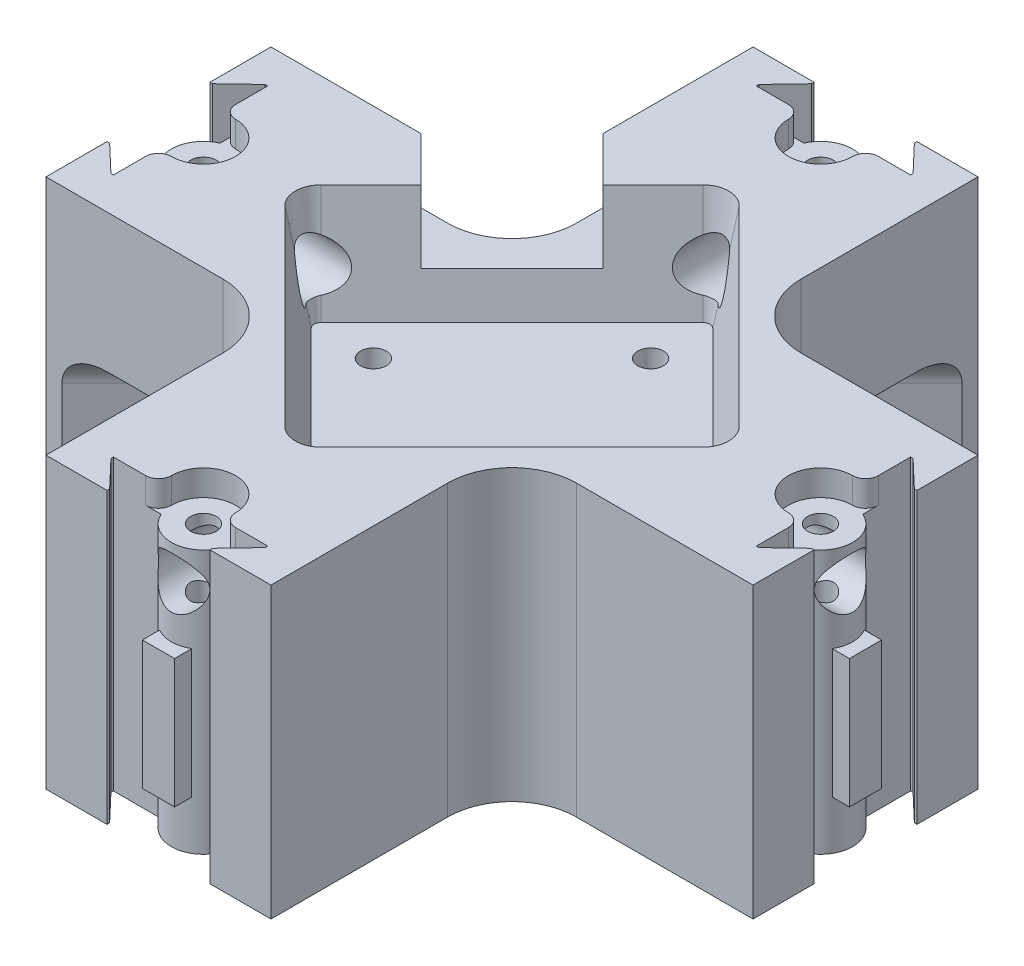
from build123d import *

# Parameters (mm, degrees)
BOSS_EXTRUDE1_DEPTH      = 45
CUT_EXTRUDE1_DEPTH       = 34.5
CUT_EXTRUDE2_DEPTH       = 46
CUT_EXTRUDE3_DEPTH       = 4
CIRPATTERN1_COUNT        = 4
SKETCH5_W                = 5
SKETCH5_H                = 20
BOSS_EXTRUDE2_DEPTH      = 4
SKETCH6_R                = 5
SKETCH6_R_2              = 2
BOSS_EXTRUDE3_DEPTH      = 45
SKETCH6_4_R              = 5
SKETCH6_4_R_2            = 2
CUT_EXTRUDE4_DEPTH       = 4
SKETCH6_5_R              = 2
CUT_EXTRUDE5_DEPTH       = 46
SKETCH5_3_W              = 5
SKETCH5_3_H              = 20
BOSS_EXTRUDE5_DEPTH      = 5
CIRPATTERN5_COUNT        = 4
CIRPATTERN6_COUNT        = 4
BOSS_EXTRUDE6_DEPTH      = 11
CUT_EXTRUDE6_DEPTH       = 16.5
CUT_EXTRUDE6_TAPER       = 10
CUT_EXTRUDE8_START       = -106
SKETCH5_7_R              = 4
CUT_EXTRUDE8_DEPTH       = 112
FILLET2_R                = 5
SKETCH14_R               = 2
CUT_EXTRUDE9_DEPTH       = 29.5000001
SKETCH17_W               = 20
SKETCH17_H               = 20
CUT_EXTRUDE11_DEPTH      = 10
CUT_EXTRUDE11_DEPTH_BACK = 15


with BuildPart() as part:
    # Sketch1 → Boss-Extrude1 (new body)
    with BuildSketch(Plane(origin=(0, 0, 0), x_dir=(1, 0, 0), z_dir=(0, 1, 0))):
        with BuildLine():
            Line((17.41755235, 71.354805723), (17.41755235, 43.854805723))
            ThreePointArc((17.41755235, 43.854805723), (20.346484538, 36.783737911), (27.41755235, 33.854805723))
            Line((27.41755235, 33.854805723), (54.91755235, 33.854805723))
            Line((54.91755235, 33.854805723), (54.91755235, -1.145194277))
            Line((54.91755235, -1.145194277), (27.41755235, -1.145194277))
            ThreePointArc((27.41755235, -1.145194277), (20.346484538, -4.074126465), (17.41755235, -11.145194277))
            Line((17.41755235, -11.145194277), (17.41755235, -38.645194277))
            Line((17.41755235, -38.645194277), (-17.58244765, -38.645194277))
            Line((-17.58244765, -38.645194277), (-17.58244765, -11.145194277))
            ThreePointArc((-17.58244765, -11.145194277), (-20.511379838, -4.074126465), (-27.58244765, -1.145194277))
            Line((-27.58244765, -1.145194277), (-55.08244765, -1.145194277))
            Line((-55.08244765, -1.145194277), (-55.08244765, 33.854805723))
            Line((-55.08244765, 33.854805723), (-27.58244765, 33.854805723))
            ThreePointArc((-27.58244765, 33.854805723), (-20.511379838, 36.783737911), (-17.58244765, 43.854805723))
            Line((-17.58244765, 43.854805723), (-17.58244765, 71.354805723))
            Line((-17.58244765, 71.354805723), (17.41755235, 71.354805723))
        make_face()
    extrude(amount=BOSS_EXTRUDE1_DEPTH)

    # Sketch1_3 → Cut-Extrude1 (cut)
    with BuildSketch(Plane(origin=(0, 0, 0), x_dir=(1, 0, 0), z_dir=(0, 1, 0))):
        with BuildLine():
            Line((17.41755235, 68.856591392), (-52.584233319, -1.145194277))
            Line((-52.584233319, -1.145194277), (-27.58244765, -1.145194277))
            ThreePointArc((-27.58244765, -1.145194277), (-20.511379838, -4.074126465), (-17.58244765, -11.145194277))
            Line((-17.58244765, -11.145194277), (-17.58244765, -36.146979946))
            Line((-17.58244765, -36.146979946), (52.419338019, 33.854805723))
            Line((52.419338019, 33.854805723), (27.41755235, 33.854805723))
            ThreePointArc((27.41755235, 33.854805723), (23.590718027, 34.616010398), (20.346484538, 36.783737911))
            ThreePointArc((20.346484538, 36.783737911), (18.178757025, 40.027971399), (17.41755235, 43.854805723))
            Line((17.41755235, 43.854805723), (17.41755235, 68.856591392))
        make_face()
    extrude(amount=CUT_EXTRUDE1_DEPTH, mode=Mode.SUBTRACT)

    # Sketch3 → Cut-Extrude2 (cut, through all)
    with BuildSketch(Plane(origin=(0, 45, 0), x_dir=(1, 0, 0), z_dir=(0, 1, 0))):
        Polygon((-55.08244765, 16.354805723), (-55.08244765, 8.354805723), (-54.68244765, 8.354805723), (-50.48244765, 4.354805723), (-50.08244765, 4.354805723), (-50.08244765, 9.354805723), (-50.08244765, 16.354805723), align=None)
        Polygon((-55.08244765, 24.354805723), (-55.08244765, 16.354805723), (-50.08244765, 16.354805723), (-50.08244765, 23.354805754), (-50.08244765, 28.354805723), (-50.48244765, 28.354805723), (-54.68244765, 24.354805723), align=None)
    cut_extrude2 = extrude(amount=-CUT_EXTRUDE2_DEPTH, mode=Mode.SUBTRACT)

    # Sketch3_3 → Cut-Extrude3 (cut)
    with BuildSketch(Plane(origin=(0, 45, 0), x_dir=(1, 0, 0), z_dir=(0, 1, 0))):
        with BuildLine():
            Line((-50.08244765, 23.354805754), (-50.08244765, 16.354805723))
            Line((-50.08244765, 16.354805723), (-50.08244765, 9.354805723))
            ThreePointArc((-50.08244765, 9.354805723), (-49.496661212, 10.769019285), (-48.08244765, 11.354805723))
            ThreePointArc((-48.08244765, 11.354805723), (-43.08244765, 16.354805723), (-48.08244765, 21.354805723))
            ThreePointArc((-48.08244765, 21.354805723), (-49.496661223, 21.940592172), (-50.08244765, 23.354805754))
        make_face()
    cut_extrude3 = extrude(amount=-CUT_EXTRUDE3_DEPTH, mode=Mode.SUBTRACT)

    # CirPattern1: Cut-Extrude2, Cut-Extrude3 ×4 about axis
    cirpattern1_axis = Axis((-0.08244765, 0, -16.354805723), (0, 1, 0))
    for i in range(1, CIRPATTERN1_COUNT):
        add(cut_extrude2.rotate(cirpattern1_axis, i * 360 / CIRPATTERN1_COUNT), mode=Mode.SUBTRACT)
        add(cut_extrude3.rotate(cirpattern1_axis, i * 360 / CIRPATTERN1_COUNT), mode=Mode.SUBTRACT)

    # Sketch5 → Boss-Extrude2 (add)
    with BuildSketch(Plane.XY.offset(33.645194277)):
        with Locations((-0.08244765, 17.6)):
            Rectangle(SKETCH5_W, SKETCH5_H)
    extrude(amount=BOSS_EXTRUDE2_DEPTH)

    # Sketch6 → Boss-Extrude3 (add, through all)
    with BuildSketch(Plane(origin=(0, 45, 0), x_dir=(1, 0, 0), z_dir=(0, 1, 0))):
        with Locations((47.91755235, 16.354805723)):
            Circle(SKETCH6_R)
        with Locations((47.91755235, 16.354805723)):
            Circle(SKETCH6_R_2, mode=Mode.SUBTRACT)
    boss_extrude3 = extrude(amount=-BOSS_EXTRUDE3_DEPTH)

    # Sketch6_4 → Cut-Extrude4 (cut)
    with BuildSketch(Plane(origin=(0, 45, 0), x_dir=(1, 0, 0), z_dir=(0, 1, 0))):
        with Locations((47.91755235, 16.354805723)):
            Circle(SKETCH6_4_R)
        with Locations((47.91755235, 16.354805723)):
            Circle(SKETCH6_4_R_2, mode=Mode.SUBTRACT)
    cut_extrude4 = extrude(amount=-CUT_EXTRUDE4_DEPTH, mode=Mode.SUBTRACT)

    # Sketch6_5 → Cut-Extrude5 (cut, through all)
    with BuildSketch(Plane(origin=(0, 45, 0), x_dir=(1, 0, 0), z_dir=(0, 1, 0))):
        with Locations((47.91755235, 16.354805723)):
            Circle(SKETCH6_5_R)
    cut_extrude5 = extrude(amount=-CUT_EXTRUDE5_DEPTH, mode=Mode.SUBTRACT)

    # Sketch5_3 → Boss-Extrude5 (add)
    with BuildSketch(Plane.XY.offset(33.645194277)):
        with Locations((-0.08244765, 17.6)):
            Rectangle(SKETCH5_3_W, SKETCH5_3_H)
    boss_extrude5 = extrude(amount=BOSS_EXTRUDE5_DEPTH)

    # CirPattern5: Boss-Extrude3, Cut-Extrude4, Cut-Extrude5 ×4 about axis
    cirpattern5_axis = Axis((-0.08244765, 0, -16.354805723), (0, 1, 0))
    for i in range(1, CIRPATTERN5_COUNT):
        add(boss_extrude3.rotate(cirpattern5_axis, i * 360 / CIRPATTERN5_COUNT))
        add(cut_extrude4.rotate(cirpattern5_axis, i * 360 / CIRPATTERN5_COUNT), mode=Mode.SUBTRACT)
        add(cut_extrude5.rotate(cirpattern5_axis, i * 360 / CIRPATTERN5_COUNT), mode=Mode.SUBTRACT)

    # CirPattern6: Boss-Extrude5 ×4 about axis
    cirpattern6_axis = Axis((-0.08244765, 0, -16.354805723), (0, 1, 0))
    for i in range(1, CIRPATTERN6_COUNT):
        add(boss_extrude5.rotate(cirpattern6_axis, i * 360 / CIRPATTERN6_COUNT))

    # Sketch12 → Boss-Extrude6 (add)
    with BuildSketch(Plane.XZ.offset(-34.5)):
        with BuildLine():
            Line((52.419338019, -33.854805723), (-17.58244765, 36.146979946))
            Line((-17.58244765, 36.146979946), (-17.58244765, 11.145194277))
            ThreePointArc((-17.58244765, 11.145194277), (-20.511379838, 4.074126465), (-27.58244765, 1.145194277))
            Line((-27.58244765, 1.145194277), (-52.584233319, 1.145194277))
            Line((-52.584233319, 1.145194277), (17.41755235, -68.856591392))
            Line((17.41755235, -68.856591392), (17.41755235, -43.855443478))
            ThreePointArc((17.41755235, -43.855443478), (20.346394354, -36.784465852), (27.417297268, -33.855443481))
            Line((27.417297268, -33.855443481), (52.419338019, -33.854805723))
        make_face()
    extrude(amount=BOSS_EXTRUDE6_DEPTH)

    # Sketch6_7 → Cut-Extrude6 (cut)
    with BuildSketch(Plane(origin=(0, 45, 0), x_dir=(1, 0, 0), z_dir=(0, 1, 0))):
        with BuildLine():
            Line((-17.760117179, 34.032475253), (-32.609359584, 19.183232848))
            ThreePointArc((-32.609359584, 19.183232848), (-33.78093246, 16.354805723), (-32.609359584, 13.526378598))
            Line((-32.609359584, 13.526378598), (-2.910874775, -16.172106212))
            ThreePointArc((-2.910874775, -16.172106212), (-0.08244765, -17.343679087), (2.745979475, -16.172106212))
            Line((2.745979475, -16.172106212), (32.444464285, 13.526378598))
            ThreePointArc((32.444464285, 13.526378598), (33.61603716, 16.354805723), (32.444464285, 19.183232848))
            Line((32.444464285, 19.183232848), (2.745979475, 48.881717658))
            ThreePointArc((2.745979475, 48.881717658), (-0.08244765, 50.053290533), (-2.910874775, 48.881717658))
            Line((-2.910874775, 48.881717658), (-17.760117179, 34.032475253))
        make_face()
    extrude(amount=-CUT_EXTRUDE6_DEPTH, taper=CUT_EXTRUDE6_TAPER, mode=Mode.SUBTRACT)

    # Sketch5_7 → Cut-Extrude8 (cut)
    with BuildSketch(Plane.XY.offset(33.645194277).offset(CUT_EXTRUDE8_START)):
        with Locations((-0.08244765, 35.6)):
            Circle(SKETCH5_7_R)
    cut_extrude8 = extrude(amount=CUT_EXTRUDE8_DEPTH, mode=Mode.SUBTRACT)

    # Mirror2: Cut-Extrude8 across plane
    add(cut_extrude8.mirror(Plane(origin=(-8.219279152, 0.000312757, -8.219114575), x_dir=(-0.707099701, 2.6906e-05, 0.707113861), z_dir=(-0.70711386, 2.6907e-05, -0.707099702))), mode=Mode.SUBTRACT)

    # Fillet2
    fillet2_edges = [part.edges().sort_by_distance(p)[0] for p in [
        (17.418445185, 23.5, 1.146087111),
        (-17.583340484, 23.5, -33.855698557),
    ]]
    fillet(fillet2_edges, radius=FILLET2_R)

    # Sketch14 → Cut-Extrude9 (cut, through all)
    with BuildSketch(Plane(origin=(0, 28.5, 0), x_dir=(1, 0, 0), z_dir=(0, 1, 0))):
        with Locations((21.484309176, 16.354805723)):
            Circle(SKETCH14_R)
        with Locations((-0.08244765, -5.211951103)):
            Circle(SKETCH14_R)
        with Locations((-21.649204476, 16.354805723)):
            Circle(SKETCH14_R)
        with Locations((-0.08244765, 37.921562549)):
            Circle(SKETCH14_R)
    extrude(amount=-CUT_EXTRUDE9_DEPTH, mode=Mode.SUBTRACT)

    # Sketch17 → Cut-Extrude11 (cut, two sides)
    with BuildSketch(Plane(origin=(-25.719519521, 0, -25.719519521), x_dir=(0.707106781, 0, -0.707106781), z_dir=(0.707106781, 0, 0.707106781))) as cut_extrude11_sk:
        with Locations((11.506294739, 45)):
            Rectangle(SKETCH17_W, SKETCH17_H)
    extrude(amount=CUT_EXTRUDE11_DEPTH, mode=Mode.SUBTRACT)
    extrude(cut_extrude11_sk.sketch, amount=-CUT_EXTRUDE11_DEPTH_BACK, mode=Mode.SUBTRACT)


solid = part.part
